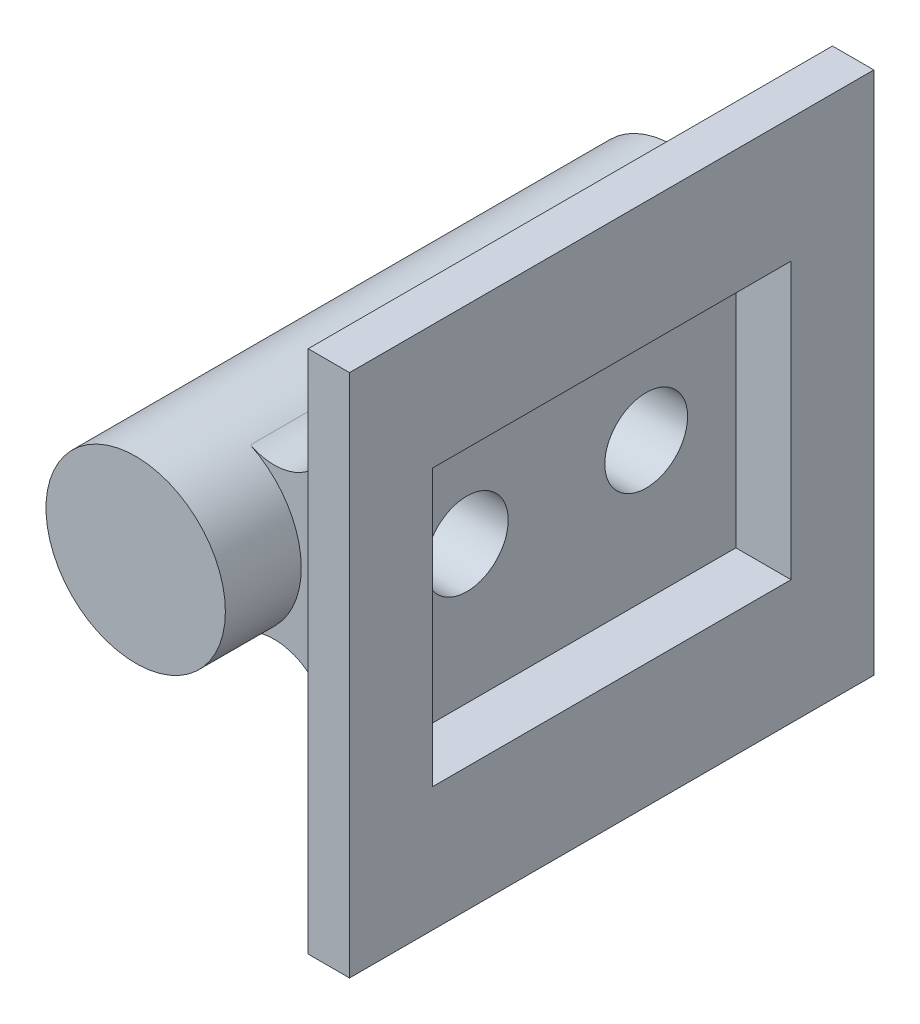
from build123d import *

# Parameters (mm, degrees)
SKETCH_1_R          = 3.25
EXTRUDE_1_DEPTH     = 19.5
SKETCH_2_W          = 14
SKETCH_2_H          = 12
EXTRUDE_2_DEPTH     = 1
EXTRUDE_3_DEPTH     = 14
FILLET_1_R          = 2
SKETCH_5_W          = 19
SKETCH_5_H          = 19
EXTRUDE_4_DEPTH     = 1.5
SKETCH_6_R          = 1.5
CUT_EXTRUDE_1_DEPTH = 11.75
SKETCH_7_W          = 13
SKETCH_7_H          = 10
CUT_EXTRUDE_2_DEPTH = 2


with BuildPart() as part:
    # ｽｹｯﾁ1 → ﾎﾞｽ - 押し出し1 (new body)
    with BuildSketch(Plane.XY):
        Circle(SKETCH_1_R)
    extrude(amount=EXTRUDE_1_DEPTH)



with BuildPart() as body_2:
    # ｽｹｯﾁ2 → ﾎﾞｽ - 押し出し2 (new body)
    with BuildSketch(Plane(origin=(5, 0, 0), x_dir=(0, 0, -1), z_dir=(1, 0, 0))):
        with Locations((-9.75, 0)):
            Rectangle(SKETCH_2_W, SKETCH_2_H)
    extrude(amount=EXTRUDE_2_DEPTH)


with BuildPart() as part_1:
    add(part.part)

    add(body_2.part)  # ﾎﾞｽ - 押し出し3 merges body 2
    # ｽｹｯﾁ3 → ﾎﾞｽ - 押し出し3 (add)
    with BuildSketch(Plane(origin=(0, 0, 2.75), x_dir=(-1, 0, 0), z_dir=(0, 0, -1))):
        Polygon((0, 0), (-5, 4.5), (-5, -4.5), align=None)
    extrude(amount=-EXTRUDE_3_DEPTH)

    # ﾌｨﾚｯﾄ1
    fillet_1_edges = [part_1.edges().sort_by_distance(p)[0] for p in [
        (2.415705975, 2.174135378, 9.75),
        (2.415705975, -2.174135378, 9.75),
        (5, 4.5, 9.75),
        (5, -4.5, 9.75),
    ]]
    fillet(fillet_1_edges, radius=FILLET_1_R)

    # ｽｹｯﾁ5 → ﾎﾞｽ - 押し出し4 (add)
    with BuildSketch(Plane(origin=(6, 0, 0), x_dir=(0, 0, -1), z_dir=(1, 0, 0))):
        with Locations((-9.75, 0)):
            Rectangle(SKETCH_5_W, SKETCH_5_H)
    extrude(amount=EXTRUDE_4_DEPTH)

    # ｽｹｯﾁ6 → ｶｯﾄ - 押し出し1 (cut, through all)
    with BuildSketch(Plane(origin=(7.5, 0, 0), x_dir=(0, 0, -1), z_dir=(1, 0, 0))):
        with Locations((-13, 0)):
            Circle(SKETCH_6_R)
        with Locations((-6.5, 0)):
            Circle(SKETCH_6_R)
    extrude(amount=-CUT_EXTRUDE_1_DEPTH, mode=Mode.SUBTRACT)

    # ｽｹｯﾁ7 → ｶｯﾄ - 押し出し2 (cut)
    with BuildSketch(Plane(origin=(7.5, 0, 0), x_dir=(0, 0, -1), z_dir=(1, 0, 0))):
        with Locations((-9.75, 0)):
            Rectangle(SKETCH_7_W, SKETCH_7_H)
    extrude(amount=-CUT_EXTRUDE_2_DEPTH, mode=Mode.SUBTRACT)


solid = part_1.part
